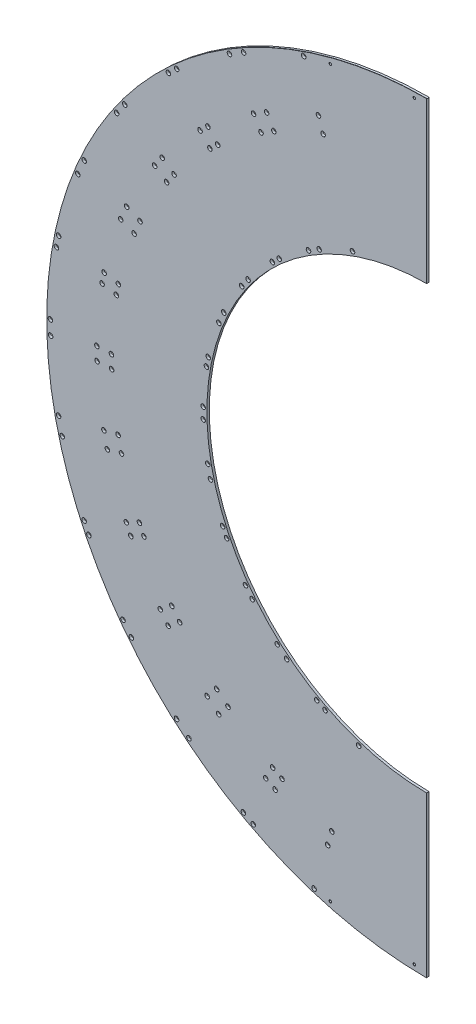
from build123d import *

# Parameters (mm, degrees)
EXTRUDE1_DEPTH                             = 1.5875
SKETCH12_W                                 = 100
SKETCH12_H                                 = 1041.21274208
EXTRUDE7_DEPTH                             = 4.175
SKETCH13_R                                 = 3
BARREL_4_ELECTRONICS_BOARD_MTG_HOLES_DEPTH = 4.175
SKETCH21_R                                 = 2.38125
F_3_0_3_DIAMETER_HOLE1_AT_2_COUNT          = 2
F_3_0_3_DIAMETER_HOLE1_AT_2_PITCH          = 111.73864719
F_3_0_3_DIAMETER_HOLE1_AT_3_COUNT          = 2
F_3_0_3_DIAMETER_HOLE1_AT_3_PITCH          = 976.22047063
F_3_0_3_DIAMETER_HOLE1_AT_4_COUNT          = 2
F_3_0_3_DIAMETER_HOLE1_AT_4_PITCH          = 986.461208195


with BuildPart() as part:
    # Sketch1 → Extrude1 (new body, symmetric)
    with BuildSketch(Plane(origin=(0, 0, 0), x_dir=(-1, 0, 0), z_dir=(0, 0, -1))):
        with BuildLine():
            Line((0, -290), (0, -500.60637104))
            ThreePointArc((0, -500.60637104), (500.60637104, 0), (0, 500.60637104))
            Line((0, 500.60637104), (0, 290))
            ThreePointArc((0, 290), (290, 0), (0, -290))
        make_face()
    extrude(amount=EXTRUDE1_DEPTH, both=True)

    # Sketch12 → Extrude7 (cut, through all)
    with BuildSketch(Plane.XY.offset(1.5875)):
        with Locations((49, 0)):
            Rectangle(SKETCH12_W, SKETCH12_H)
    extrude(amount=-EXTRUDE7_DEPTH, mode=Mode.SUBTRACT)

    # Sketch13 → barrel 4 electronics board mtg holes (cut, through all)
    with BuildSketch(Plane.XY.offset(1.5875)):
        with Locations((-149.027159262, -472.762346007)):
            Circle(SKETCH13_R)
        with Locations((-229.030775517, -439.611457842)):
            Circle(SKETCH13_R)
        with Locations((-200.305656159, -385.701185)):
            Circle(SKETCH13_R)
        with Locations((-90.372682799, -280.793123498)):
            Circle(SKETCH13_R)
        with Locations((-134.716488576, -262.418497263)):
            Circle(SKETCH13_R)
        with Locations((-191.277090963, -368.875757502)):
            Circle(SKETCH13_R)
        with Locations((-125.685211585, -396.054892141)):
            Circle(SKETCH13_R)
        with Locations((-131.203225491, -414.334977549)):
            Circle(SKETCH13_R)
        with Locations((-185.236375962, -229.563684019)):
            Circle(SKETCH13_R)
        with Locations((-145.552251772, -256.566837304)):
            Circle(SKETCH13_R)
        with Locations((-262.251913926, -322.304489019)):
            Circle(SKETCH13_R)
        with Locations((-203.552480229, -362.246653252)):
            Circle(SKETCH13_R)
        with Locations((-212.670398488, -379.023827228)):
            Circle(SKETCH13_R)
        with Locations((-274.511492017, -336.94391336)):
            Circle(SKETCH13_R)
        with Locations((-313.593326442, -383.891333076)):
            Circle(SKETCH13_R)
        with Locations((-241.996552384, -432.609522126)):
            Circle(SKETCH13_R)
        with Locations((-235.814336686, 177.210605251)):
            Circle(SKETCH13_R)
        with Locations((-244.198147281, 165.466808951)):
            Circle(SKETCH13_R)
        with Locations((-267.801228951, 123.670941504)):
            Circle(SKETCH13_R)
        with Locations((-274.220578361, 108.697168332)):
            Circle(SKETCH13_R)
        with Locations((-288.219019188, 62.783731797)):
            Circle(SKETCH13_R)
        with Locations((-290.588395503, 50.698958559)):
            Circle(SKETCH13_R)
        with Locations((-294.963721568, 2.898785737)):
            Circle(SKETCH13_R)
        with Locations((-294.752578613, -11.528980905)):
            Circle(SKETCH13_R)
        with Locations((-288.980363872, -59.18064968)):
            Circle(SKETCH13_R)
        with Locations((-285.272280948, -75.044824757)):
            Circle(SKETCH13_R)
        with Locations((-269.324294065, -120.318014554)):
            Circle(SKETCH13_R)
        with Locations((-264.067598146, -131.454568614)):
            Circle(SKETCH13_R)
        with Locations((-239.251564204, -172.541847173)):
            Circle(SKETCH13_R)
        with Locations((-230.527688676, -184.035281274)):
            Circle(SKETCH13_R)
        with Locations((-197.627930175, -218.986760364)):
            Circle(SKETCH13_R)
        with Locations((-98.550747697, 278.028326126)):
            Circle(SKETCH13_R)
        with Locations((-142.337872197, 258.363948992)):
            Circle(SKETCH13_R)
        with Locations((-156.384901193, 250.111500493)):
            Circle(SKETCH13_R)
        with Locations((-194.878650202, 221.436924869)):
            Circle(SKETCH13_R)
        with Locations((-203.951442175, 213.109852505)):
            Circle(SKETCH13_R)
        with Locations((-343.032910916, 234.488106368)):
            Circle(SKETCH13_R)
        with Locations((-408.683039777, 280.520058104)):
            Circle(SKETCH13_R)
        with Locations((-398.056492215, 295.405414652)):
            Circle(SKETCH13_R)
        with Locations((-348.667631576, 259.45836408)):
            Circle(SKETCH13_R)
        with Locations((-333.196273297, 248.266980207)):
            Circle(SKETCH13_R)
        with Locations((-286.065741833, 301.367950103)):
            Circle(SKETCH13_R)
        with Locations((-299.014620963, 315.401357718)):
            Circle(SKETCH13_R)
        with Locations((-340.570520035, 360.173639906)):
            Circle(SKETCH13_R)
        with Locations((-329.714266152, 370.13758617)):
            Circle(SKETCH13_R)
        with Locations((-288.661613712, 324.903420679)):
            Circle(SKETCH13_R)
        with Locations((-275.787549963, 310.801346982)):
            Circle(SKETCH13_R)
        with Locations((-260.265127314, 421.871299692)):
            Circle(SKETCH13_R)
        with Locations((-228.675521506, 369.587967694)):
            Circle(SKETCH13_R)
        with Locations((-218.848879553, 353.215823426)):
            Circle(SKETCH13_R)
        with Locations((-201.989480277, 363.120503218)):
            Circle(SKETCH13_R)
        with Locations((-211.50653657, 379.674525071)):
            Circle(SKETCH13_R)
        with Locations((-241.796914993, 432.721136414)):
            Circle(SKETCH13_R)
        with Locations((-162.797644542, 468.198950161)):
            Circle(SKETCH13_R)
        with Locations((-143.271600892, 410.318179439)):
            Circle(SKETCH13_R)
        with Locations((-137.221025288, 392.207394396)):
            Circle(SKETCH13_R)
        with Locations((-358.642819798, 245.485412616)):
            Circle(SKETCH13_R)
        with Locations((-480.134353204, -123.224725091)):
            Circle(SKETCH13_R)
        with Locations((-420.828039406, -108.588771286)):
            Circle(SKETCH13_R)
        with Locations((-402.276127298, -104.068090241)):
            Circle(SKETCH13_R)
        with Locations((-485.009523801, -102.367435361)):
            Circle(SKETCH13_R)
        with Locations((-425.360244749, -89.198779068)):
            Circle(SKETCH13_R)
        with Locations((-406.726609359, -85.027732177)):
            Circle(SKETCH13_R)
        with Locations((-415.264676998, -14.542972115)):
            Circle(SKETCH13_R)
        with Locations((-434.355279388, -14.941595228)):
            Circle(SKETCH13_R)
        with Locations((-495.423561231, -16.395882948)):
            Circle(SKETCH13_R)
        with Locations((-495.691186629, 1.891427661)):
            Circle(SKETCH13_R)
        with Locations((-434.606500559, 2.224785888)):
            Circle(SKETCH13_R)
        with Locations((-415.512408826, 2.384976161)):
            Circle(SKETCH13_R)
        with Locations((-409.040572355, 73.089398461)):
            Circle(SKETCH13_R)
        with Locations((-427.788284107, 76.713388536)):
            Circle(SKETCH13_R)
        with Locations((-487.797369186, 88.130906127)):
            Circle(SKETCH13_R)
        with Locations((-484.962238512, 102.591214132)):
            Circle(SKETCH13_R)
        with Locations((-425.084577217, 90.503382326)):
            Circle(SKETCH13_R)
        with Locations((-406.356403639, 86.779739694)):
            Circle(SKETCH13_R)
        with Locations((-385.650376583, 154.693364569)):
            Circle(SKETCH13_R)
        with Locations((-403.270340262, 162.051820925)):
            Circle(SKETCH13_R)
        with Locations((-459.706718187, 185.42670588)):
            Circle(SKETCH13_R)
        with Locations((-451.266932956, 205.113347251)):
            Circle(SKETCH13_R)
        with Locations((-395.424288734, 180.353519177)):
            Circle(SKETCH13_R)
        with Locations((-377.945802553, 172.665052435)):
            Circle(SKETCH13_R)
        with Locations((-329.885017323, -369.985412342)):
            Circle(SKETCH13_R)
        with Locations((-289.657072459, -324.016265602)):
            Circle(SKETCH13_R)
        with Locations((-277.124394093, -309.609948482)):
            Circle(SKETCH13_R)
        with Locations((-325.788620209, -257.910885661)):
            Circle(SKETCH13_R)
        with Locations((-340.925862789, -269.550210687)):
            Circle(SKETCH13_R)
        with Locations((-389.241664952, -306.927118817)):
            Circle(SKETCH13_R)
        with Locations((-400.299247559, -292.359098377)):
            Circle(SKETCH13_R)
        with Locations((-351.305665556, -255.875144061)):
            Circle(SKETCH13_R)
        with Locations((-336.02425247, -244.425759183)):
            Circle(SKETCH13_R)
        with Locations((-372.731302676, -183.650826314)):
            Circle(SKETCH13_R)
        with Locations((-389.977318449, -191.847468306)):
            Circle(SKETCH13_R)
        with Locations((-445.071508796, -218.230799976)):
            Circle(SKETCH13_R)
        with Locations((-451.36152687, -204.905105017)):
            Circle(SKETCH13_R)
        with Locations((-395.975759848, -179.139492053)):
            Circle(SKETCH13_R)
        with Locations((-378.686396701, -171.034683482)):
            Circle(SKETCH13_R)
    extrude(amount=-BARREL_4_ELECTRONICS_BOARD_MTG_HOLES_DEPTH, mode=Mode.SUBTRACT)

    # Cut-Sweep1: sweep along a path in Sketch22
    with BuildLine(Plane.XY.offset(1.5875)) as cut_sweep1_path:
        ThreePointArc((0, 500.60637104), (-500.60637104, 0), (0, -500.60637104))
    # Sketch21 → Cut-Sweep1 (sweep, cut)
    with BuildSketch(Plane(origin=(0, 0, 0), x_dir=(0, 0, -1), z_dir=(1, 0, 0))):
        with Locations((0, 502.38125)):
            Circle(SKETCH21_R)
    sweep(path=cut_sweep1_path.line, mode=Mode.SUBTRACT)

    # Sketch23 → 3.0 _3_ Diameter Hole1 (revolve, cut)
    with BuildSketch(Plane(origin=(-17.223992232, 493.230604097, 1.5875), x_dir=(0, -1, 0), z_dir=(1, 0, 0))):
        Polygon((0, 0), (0, 3.175), (1.7, 3.175), (1.5, 2.975), (1.5, 0.2), (1.7, 0), align=None)
    f_3_0_3_diameter_hole1 = revolve(axis=Axis((-17.223992232, 493.230604097, 7.9375), (0, 0, -1)), mode=Mode.SUBTRACT)

    # 3.0 _3_ Diameter Hole1 at 2: 3.0 _3_ Diameter Hole1 ×2
    with Locations(*[Vector(-0.989015863, -0.147809411, 0) * (i * F_3_0_3_DIAMETER_HOLE1_AT_2_PITCH) for i in range(1, F_3_0_3_DIAMETER_HOLE1_AT_2_COUNT)]):
        add(f_3_0_3_diameter_hole1, mode=Mode.SUBTRACT)

    # 3.0 _3_ Diameter Hole1 at 3: 3.0 _3_ Diameter Hole1 ×2
    with Locations(*[Vector(-0.113203214, -0.993571856, 0) * (i * F_3_0_3_DIAMETER_HOLE1_AT_3_PITCH) for i in range(1, F_3_0_3_DIAMETER_HOLE1_AT_3_COUNT)]):
        add(f_3_0_3_diameter_hole1, mode=Mode.SUBTRACT)

    # 3.0 _3_ Diameter Hole1 at 4: 3.0 _3_ Diameter Hole1 ×2
    with Locations(*[(0, -i * F_3_0_3_DIAMETER_HOLE1_AT_4_PITCH, 0) for i in range(1, F_3_0_3_DIAMETER_HOLE1_AT_4_COUNT)]):
        add(f_3_0_3_diameter_hole1, mode=Mode.SUBTRACT)


solid = part.part
